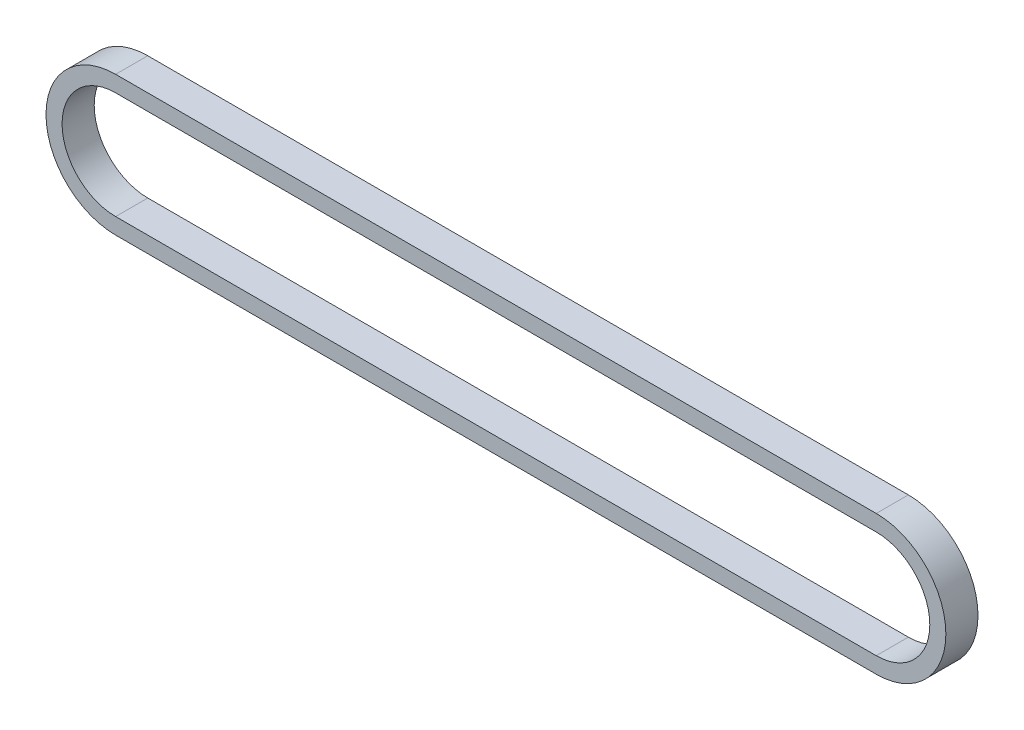
from build123d import *

# Parameters (mm, degrees)
BOSS_EXTRUDE1_DEPTH = 3


with BuildPart() as part:
    # Sketch1 → Boss-Extrude1 (new body)
    with BuildSketch(Plane.XY):
        with BuildLine():
            Line((-35.5, 6.5), (35.5, 6.5))
            ThreePointArc((35.5, 6.5), (42, 0), (35.5, -6.5))
            Line((35.5, -6.5), (-35.5, -6.5))
            ThreePointArc((-35.5, -6.5), (-42, 0), (-35.5, 6.5))
        make_face()
        with BuildLine():
            Line((-35.5, 5), (35.5, 5))
            ThreePointArc((35.5, 5), (40.5, 0), (35.5, -5))
            Line((35.5, -5), (-35.5, -5))
            ThreePointArc((-35.5, -5), (-40.5, 0), (-35.5, 5))
        make_face(mode=Mode.SUBTRACT)
    extrude(amount=BOSS_EXTRUDE1_DEPTH)


solid = part.part
